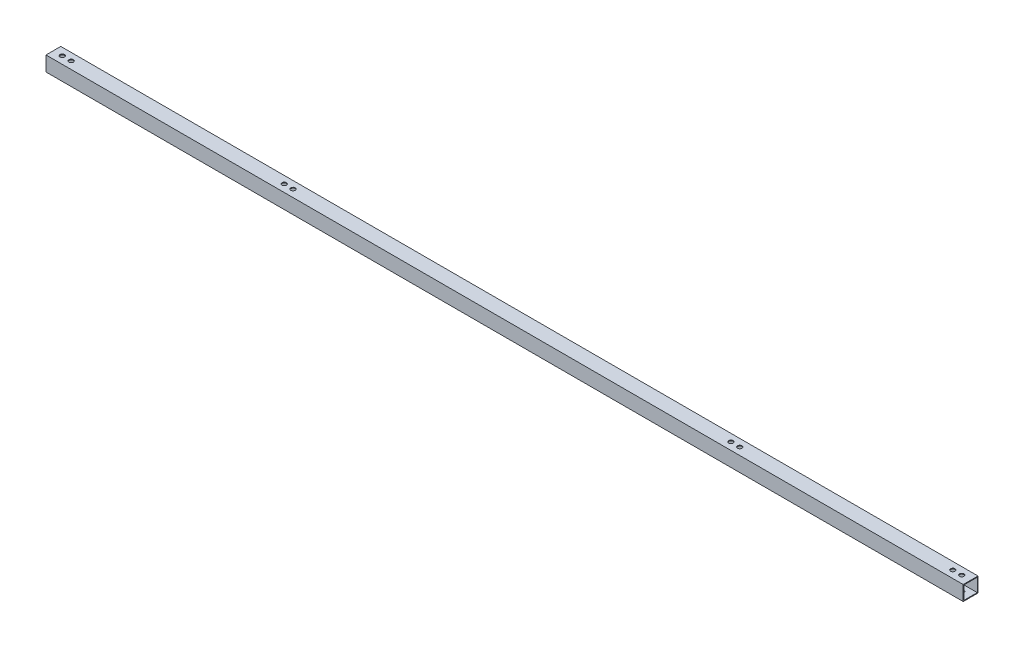
from build123d import *

# Parameters (mm, degrees)
SKETCH1_W           = 20
SKETCH1_H           = 20
SKETCH1_W_2         = 18
SKETCH1_H_2         = 18
BOSS_EXTRUDE1_DEPTH = 1240
SKETCH2_R           = 3
CUT_EXTRUDE1_DEPTH  = 1240


with BuildPart() as part:
    # Sketch1 → Boss-Extrude1 (new body)
    with BuildSketch(Plane(origin=(0, 0, 0), x_dir=(0, 0, -1), z_dir=(1, 0, 0))):
        Rectangle(SKETCH1_W, SKETCH1_H)
        Rectangle(SKETCH1_W_2, SKETCH1_H_2, mode=Mode.SUBTRACT)
    extrude(amount=BOSS_EXTRUDE1_DEPTH)

    # Sketch2 → Cut-Extrude1 (cut)
    with BuildSketch(Plane(origin=(0, 10, 0), x_dir=(1, 0, 0), z_dir=(0, 1, 0))):
        with Locations((12, 0)):
            Circle(SKETCH2_R)
        with Locations((24, 0)):
            Circle(SKETCH2_R)
        with Locations((1216, 0)):
            Circle(SKETCH2_R)
        with Locations((1228, 0)):
            Circle(SKETCH2_R)
        with Locations((324, 0)):
            Circle(SKETCH2_R)
        with Locations((312, 0)):
            Circle(SKETCH2_R)
        with Locations((916, 0)):
            Circle(SKETCH2_R)
        with Locations((928, 0)):
            Circle(SKETCH2_R)
    extrude(amount=-CUT_EXTRUDE1_DEPTH, mode=Mode.SUBTRACT)


solid = part.part
